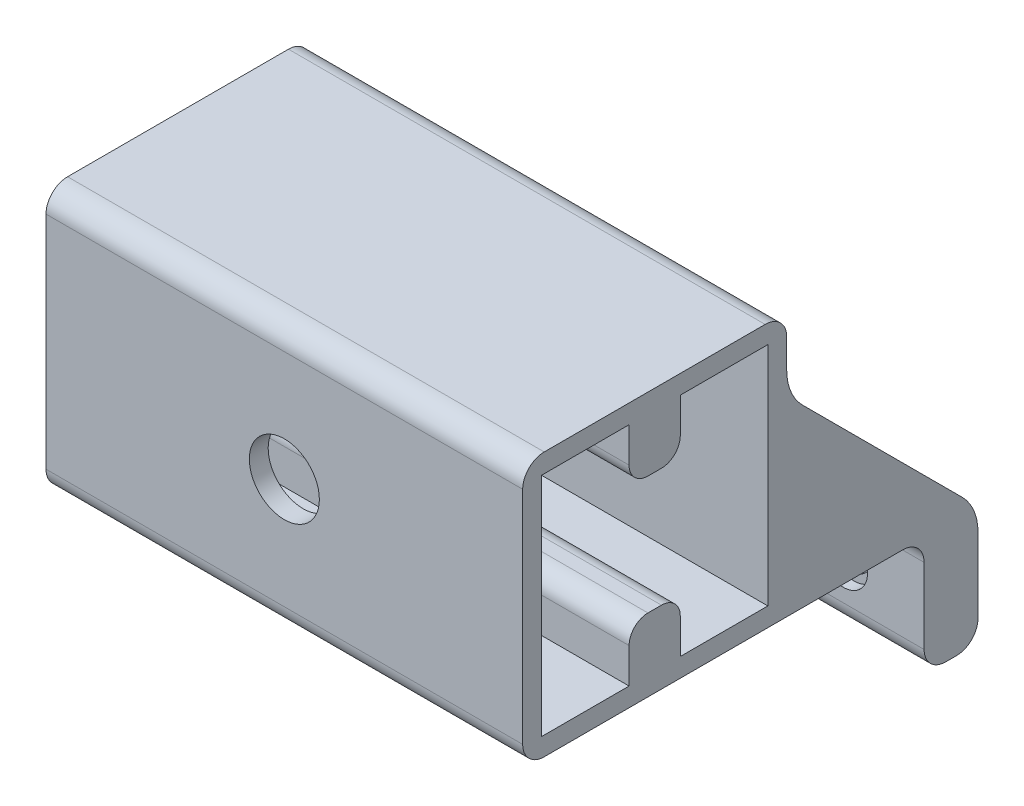
from build123d import *

# Parameters (mm, degrees)
BOSS_EXTRUDE1_DEPTH      = 22.115
BOSS_EXTRUDE1_DEPTH_BACK = 22.115
SKETCH2_R                = 3.25
CUT_EXTRUDE1_DEPTH       = 11.115
SKETCH3_R                = 2.25
CUT_EXTRUDE2_DEPTH       = 1
SKETCH4_R                = 1.5
CUT_EXTRUDE3_DEPTH       = 6


with BuildPart() as part:
    # Sketch1 → Boss-Extrude1 (new, two sides: drawn at the far end of the back side and taken through both)
    with BuildSketch(Plane(origin=(0, 0, 0), x_dir=(0, 0, -1), z_dir=(1, 0, 0)).offset(-BOSS_EXTRUDE1_DEPTH_BACK)):
        with BuildLine():
            Line((-10.25, -12.25), (23, -12.25))
            ThreePointArc((23, -12.25), (24.414213562, -12.835786438), (25, -14.25))
            Line((25, -14.25), (25, -21.25))
            ThreePointArc((25, -21.25), (25.585786438, -22.664213562), (27, -23.25))
            Line((27, -23.25), (28, -23.25))
            ThreePointArc((28, -23.25), (29.414213562, -22.664213562), (30, -21.25))
            Line((30, -21.25), (30, -14.321067812))
            ThreePointArc((30, -14.321067812), (29.886434949, -13.261467186), (29.550898606, -12.25))
            ThreePointArc((29.550898606, -12.25), (29.108985632, -11.472166783), (28.535533906, -10.785533906))
            Line((28.535533906, -10.785533906), (13.714466094, 4.035533906))
            ThreePointArc((13.714466094, 4.035533906), (12.630602337, 5.65765065), (12.25, 7.571067812))
            Line((12.25, 7.571067812), (12.25, 10.25))
            ThreePointArc((12.25, 10.25), (11.664213562, 11.664213562), (10.25, 12.25))
            Line((10.25, 12.25), (-10.25, 12.25))
            ThreePointArc((-10.25, 12.25), (-11.664213562, 11.664213562), (-12.25, 10.25))
            Line((-12.25, 10.25), (-12.25, -10.25))
            ThreePointArc((-12.25, -10.25), (-11.664213562, -11.664213562), (-10.25, -12.25))
        make_face()
        with BuildLine():
            Line((-2.375, -7.25), (-2.375, -10.5))
            Line((-2.375, -10.5), (-10.5, -10.5))
            Line((-10.5, -10.5), (-10.5, 10.5))
            Line((-10.5, 10.5), (-2.375, 10.5))
            Line((-2.375, 10.5), (-2.375, 7.25))
            ThreePointArc((-2.375, 7.25), (-1.862436867, 6.012563133), (-0.625, 5.5))
            Line((-0.625, 5.5), (0.625, 5.5))
            ThreePointArc((0.625, 5.5), (1.862436867, 6.012563133), (2.375, 7.25))
            Line((2.375, 7.25), (2.375, 10.5))
            Line((2.375, 10.5), (10.5, 10.5))
            Line((10.5, 10.5), (10.5, -10.5))
            Line((10.5, -10.5), (2.375, -10.5))
            Line((2.375, -10.5), (2.375, -7.25))
            ThreePointArc((2.375, -7.25), (1.862436867, -6.012563133), (0.625, -5.5))
            Line((0.625, -5.5), (-0.625, -5.5))
            ThreePointArc((-0.625, -5.5), (-1.862436867, -6.012563133), (-2.375, -7.25))
        make_face(mode=Mode.SUBTRACT)
    extrude(amount=BOSS_EXTRUDE1_DEPTH + BOSS_EXTRUDE1_DEPTH_BACK)

    # Sketch2 → Cut-Extrude1 (cut)
    with BuildSketch(Plane.XY.offset(12.25)):
        Circle(SKETCH2_R)
    extrude(amount=-CUT_EXTRUDE1_DEPTH, mode=Mode.SUBTRACT)

    # Sketch3 → Cut-Extrude2 (cut)
    with BuildSketch(Plane.XY.offset(-25)):
        with Locations((14.615, -17.75)):
            Circle(SKETCH3_R)
        with Locations((-5.385, -17.75)):
            Circle(SKETCH3_R)
    extrude(amount=-CUT_EXTRUDE2_DEPTH, mode=Mode.SUBTRACT)

    # Sketch4 → Cut-Extrude3 (cut)
    with BuildSketch(Plane.XY.offset(-26)):
        with Locations((-5.385, -17.75)):
            Circle(SKETCH4_R)
        with Locations((14.615, -17.75)):
            Circle(SKETCH4_R)
    extrude(amount=-CUT_EXTRUDE3_DEPTH, mode=Mode.SUBTRACT)


solid = part.part
